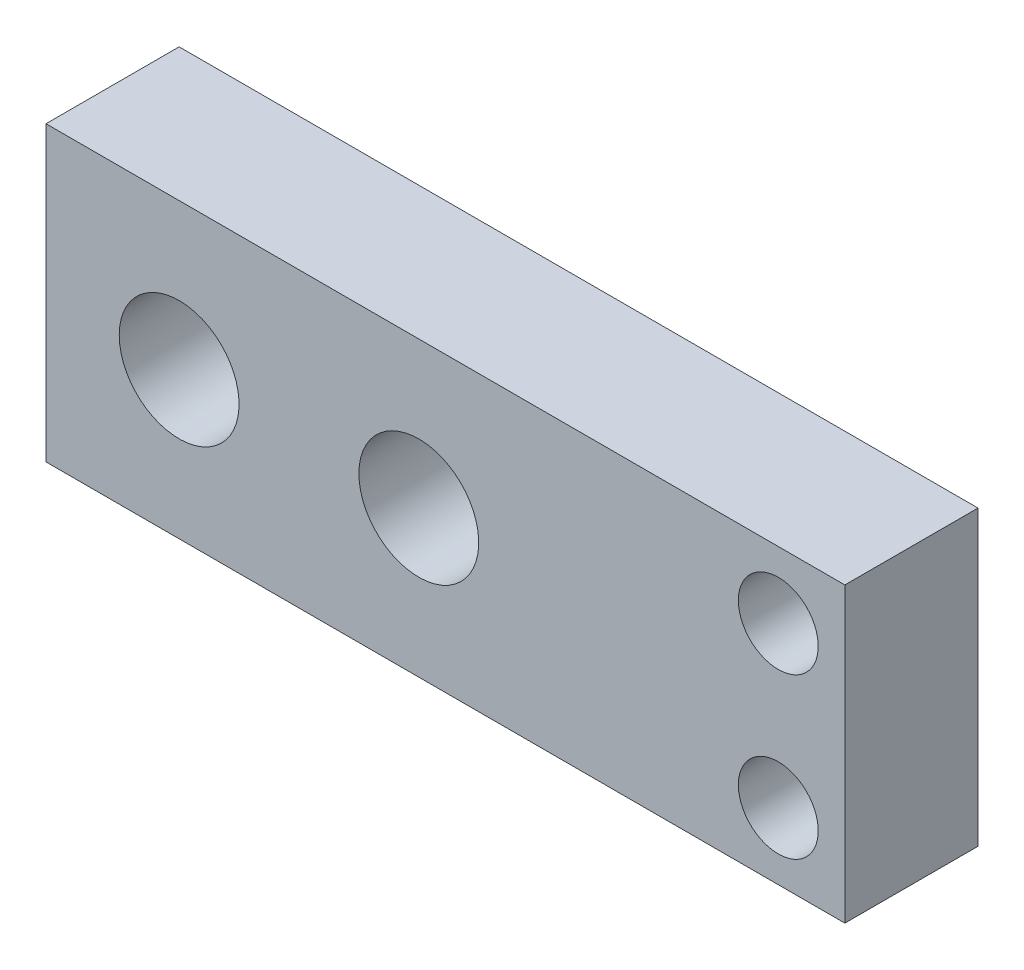
from build123d import *

# Parameters (mm, degrees)
SKETCH1_W           = 60
SKETCH1_H           = 22
BOSS_EXTRUDE1_DEPTH = 10
SKETCH3_R           = 4.5
CUT_EXTRUDE1_DEPTH  = 60
SKETCH4_R           = 3
CUT_EXTRUDE2_DEPTH  = 60


with BuildPart() as part:
    # Sketch1 → Boss-Extrude1 (new body)
    with BuildSketch(Plane.XY):
        Rectangle(SKETCH1_W, SKETCH1_H)
    extrude(amount=BOSS_EXTRUDE1_DEPTH)

    # Sketch3 → Cut-Extrude1 (cut)
    with BuildSketch(Plane(origin=(0, 0, 0), x_dir=(-1, 0, 0), z_dir=(0, 0, -1))):
        with Locations((20, 0)):
            Circle(SKETCH3_R)
        with Locations((2, 0)):
            Circle(SKETCH3_R)
    extrude(amount=-CUT_EXTRUDE1_DEPTH, mode=Mode.SUBTRACT)

    # Sketch4 → Cut-Extrude2 (cut)
    with BuildSketch(Plane(origin=(0, 0, 0), x_dir=(-1, 0, 0), z_dir=(0, 0, -1))):
        with Locations((-25, 6)):
            Circle(SKETCH4_R)
        with Locations((-25, -6)):
            Circle(SKETCH4_R)
    extrude(amount=-CUT_EXTRUDE2_DEPTH, mode=Mode.SUBTRACT)


solid = part.part
